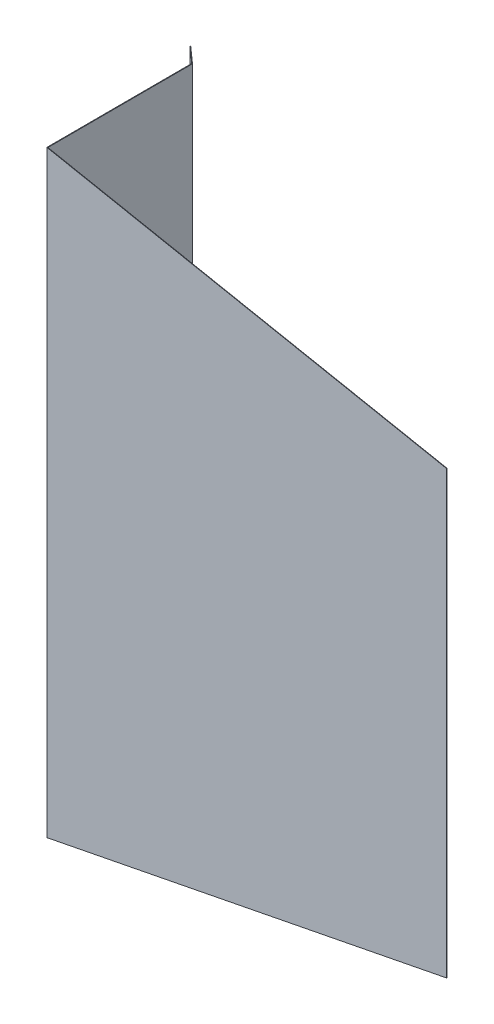
from build123d import *

# Parameters (mm, degrees)
WYCI_GNI_CIE_CIENKA_CIANKA1_DEPTH      = 400
WYCI_GNI_CIE_CIENKA_CIANKA1_DEPTH_BACK = 400


with BuildPart() as part:
    # Szkic3 → Wyciągnięcie-cienka ścianka1 (new, two sides)
    with BuildSketch(Plane(origin=(0, 0, 0), x_dir=(1, 0, 0), z_dir=(0, 1, 0))) as wyci_gni_cie_cienka_cianka1_sk:
        Polygon((956.655966162, -465.583132528), (969.891434648, -477.079346089), (970.078511471, -618.499346089), (1360.07269303, -618.499346089), (1360.07269303, -618.999346089), (969.579172456, -618.999346089), (969.391736143, -477.307590729), (956.328086187, -465.960617259), align=None)
    extrude(amount=WYCI_GNI_CIE_CIENKA_CIANKA1_DEPTH)
    extrude(wyci_gni_cie_cienka_cianka1_sk.sketch, amount=-WYCI_GNI_CIE_CIENKA_CIANKA1_DEPTH_BACK)

    # Cięcie powierzchnią1
    split(bisect_by=Plane(origin=(90.906039695, -464.075841363, 0), x_dir=(-0.9813493581662637, -0.19223276834780917, 0), z_dir=(-0.19223276834780917, 0.9813493581662637, 0)), keep=Keep.TOP)

    # Cięcie powierzchnią2
    split(bisect_by=Plane(origin=(90.906039695, 464.075841363, 0), x_dir=(-0.9813493581662637, 0.19223276834780917, 0), z_dir=(0.19223276834780917, 0.9813493581662637, 0)), keep=Keep.BOTTOM)


solid = part.part
